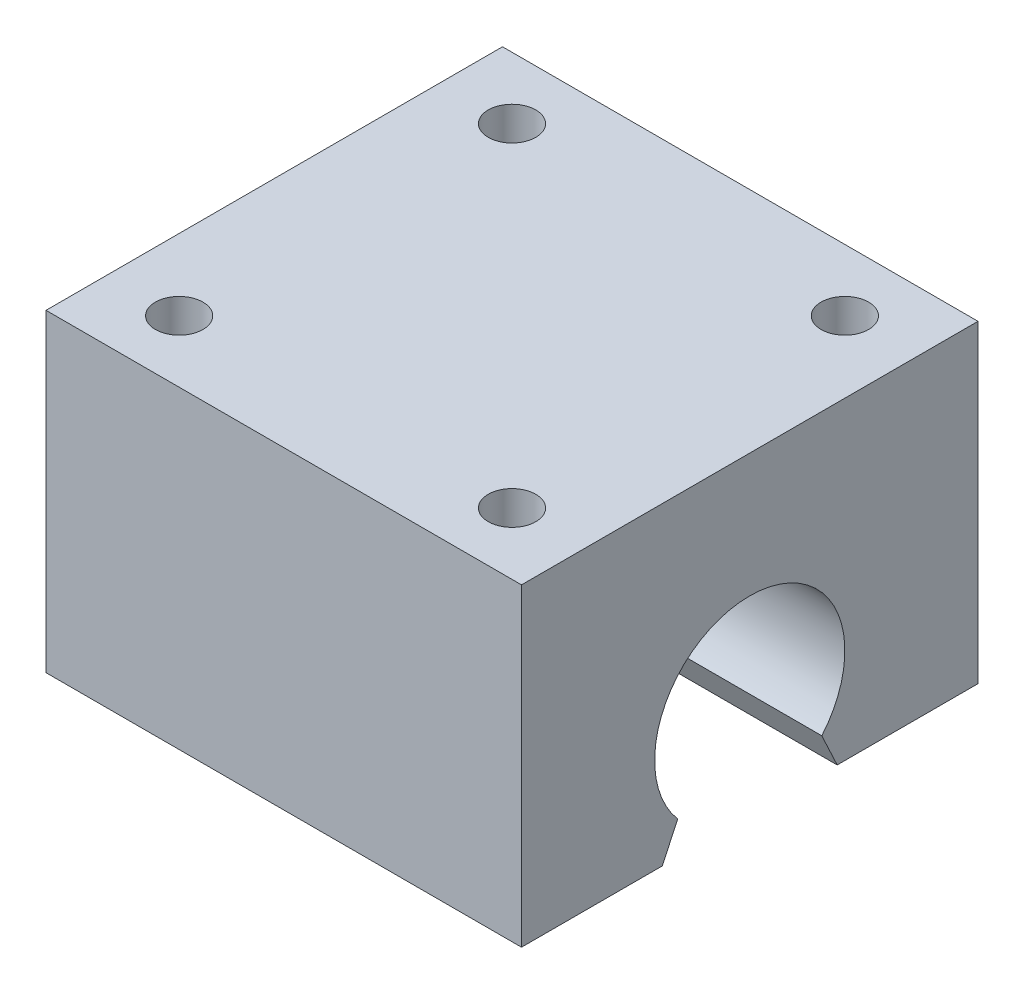
from build123d import *

# Parameters (mm, degrees)
BOSS_EXTRUDE1_DEPTH = 50
SKETCH2_R           = 2.5
CUT_EXTRUDE1_DEPTH  = 5


with BuildPart() as part:
    # Sketch1 → Boss-Extrude1 (new body)
    with BuildSketch(Plane(origin=(0, 0, 0), x_dir=(0, 0, -1), z_dir=(1, 0, 0))):
        with BuildLine():
            Line((24, -16.5), (9.19407636, -16.5))
            Line((9.19407636, -16.5), (7.575142847, -13.028185878))
            ThreePointArc((7.575142847, -13.028185878), (0, 3.5), (-7.575142847, -13.028185878))
            Line((-7.575142847, -13.028185878), (-9.19407636, -16.5))
            Line((-9.19407636, -16.5), (-24, -16.5))
            Line((-24, -16.5), (-24, 16.5))
            Line((-24, 16.5), (24, 16.5))
            Line((24, 16.5), (24, -16.5))
        make_face()
    extrude(amount=BOSS_EXTRUDE1_DEPTH)

    # Sketch2 → Cut-Extrude1 (cut)
    with BuildSketch(Plane(origin=(0, 16.5, 0), x_dir=(1, 0, 0), z_dir=(0, 1, 0))):
        with Locations((7.5, 17.5)):
            Circle(SKETCH2_R)
        with Locations((42.5, 17.5)):
            Circle(SKETCH2_R)
        with Locations((42.5, -17.5)):
            Circle(SKETCH2_R)
        with Locations((7.5, -17.5)):
            Circle(SKETCH2_R)
    extrude(amount=-CUT_EXTRUDE1_DEPTH, mode=Mode.SUBTRACT)


solid = part.part
